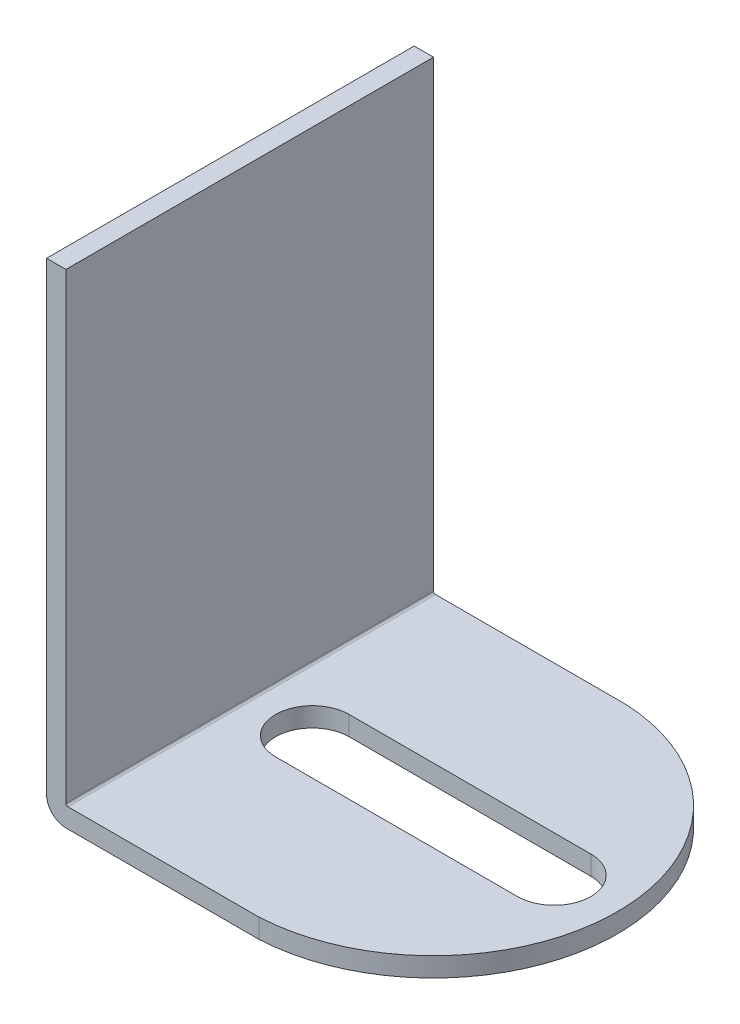
from build123d import *

# Parameters (mm, degrees)
SKETCH1_W           = 19
SKETCH1_H           = 2
BOSS_EXTRUDE1_DEPTH = 38
CUT_EXTRUDE1_DEPTH  = 38


with BuildPart() as part:
    # Sketch1 → Boss-Extrude1 (new body)
    with BuildSketch(Plane.XY):
        with BuildLine():
            ThreePointArc((-18.000000186, -22.8), (-17.941421543, -22.941421356), (-17.800000186, -23))
            Line((-17.800000186, -23), (1.000000186, -23))
            Line((1.000000186, -23), (1.000000186, -25))
            Line((1.000000186, -25), (-18.000000186, -25))
            ThreePointArc((-18.000000186, -25), (-19.414213749, -24.414213562), (-20.000000186, -23))
            Line((-20.000000186, -23), (-20.000000186, 23))
            Line((-20.000000186, 23), (-20.000000186, 25))
            Line((-20.000000186, 25), (-18.000000186, 25))
            Line((-18.000000186, 25), (-18.000000186, 23))
            Line((-18.000000186, 23), (-18.000000186, -22.8))
        make_face()
        with Locations((10.500000186, -24)):
            Rectangle(SKETCH1_W, SKETCH1_H)
    extrude(amount=BOSS_EXTRUDE1_DEPTH)

    # Sketch2 → Cut-Extrude1 (cut)
    with BuildSketch(Plane.XZ.offset(25)):
        with BuildLine():
            Line((20.000000186, 0), (20.000000186, 19))
            ThreePointArc((20.000000186, 19), (14.768114469, 5.896541545), (1.950000354, 0))
            Line((1.950000354, 0), (20.000000186, 0))
        make_face()
        with BuildLine():
            Line((20.000000186, 38), (1.950000354, 38))
            ThreePointArc((1.950000354, 38), (14.768114469, 32.103458455), (20.000000186, 19))
            Line((20.000000186, 19), (20.000000186, 38))
        make_face()
        with BuildLine():
            Line((13.470634361, 22.80060415), (-11.520634006, 22.80060415))
            ThreePointArc((-11.520634006, 22.80060415), (-15.321238156, 19), (-11.520634006, 15.19939585))
            Line((-11.520634006, 15.19939585), (13.470634361, 15.19939585))
            ThreePointArc((13.470634361, 15.19939585), (17.27123851, 19), (13.470634361, 22.80060415))
        make_face()
    extrude(amount=-CUT_EXTRUDE1_DEPTH, mode=Mode.SUBTRACT)


solid = part.part
